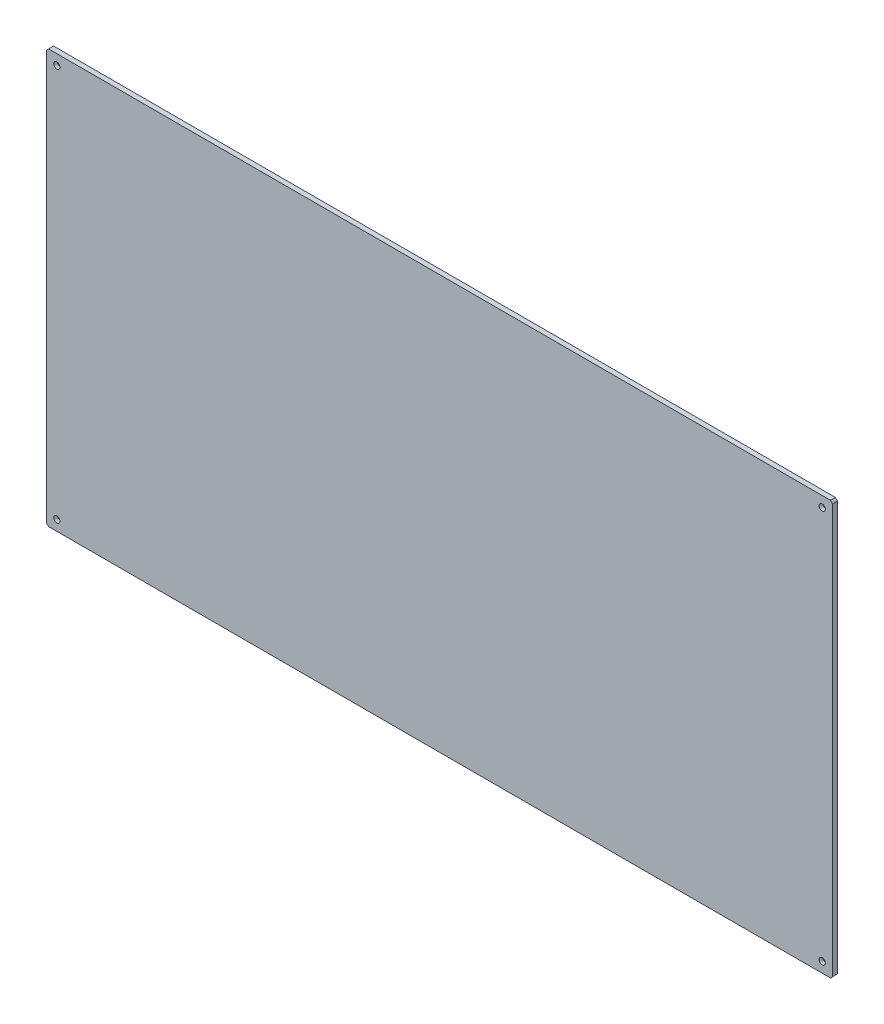
from build123d import *

# Parameters (mm, degrees)
SKETCH_1_W                = 1900
SKETCH_1_H                = 1000
EXTRUDE_1_DEPTH           = 6
HOLE_WIZARD_1_D           = 9
HOLE_WIZARD_1_CBORE_D     = 15
HOLE_WIZARD_1_CBORE_DEPTH = 9
CHAMFER_1_SIZE            = 5


with BuildPart() as part:
    # 草图1 → 凸台-拉伸1 (new body, symmetric)
    with BuildSketch(Plane.XY):
        Rectangle(SKETCH_1_W, SKETCH_1_H)
    extrude(amount=EXTRUDE_1_DEPTH, both=True)

    # 打孔尺寸(%根据)内六角圆柱头螺钉的类型1 (through all)
    with Locations(Plane.XY.offset(6)):
        with Locations((925, 475), (925, -475), (-925, -475), (-925, 475)):
            CounterBoreHole(HOLE_WIZARD_1_D / 2, HOLE_WIZARD_1_CBORE_D / 2, HOLE_WIZARD_1_CBORE_DEPTH)

    # 倒角1
    chamfer_1_edges = [part.edges().sort_by_distance(p)[0] for p in [
        (-950, 500, 0),
        (950, 500, 0),
        (950, -500, 0),
        (-950, -500, 0),
    ]]
    chamfer(chamfer_1_edges, length=CHAMFER_1_SIZE)


solid = part.part
